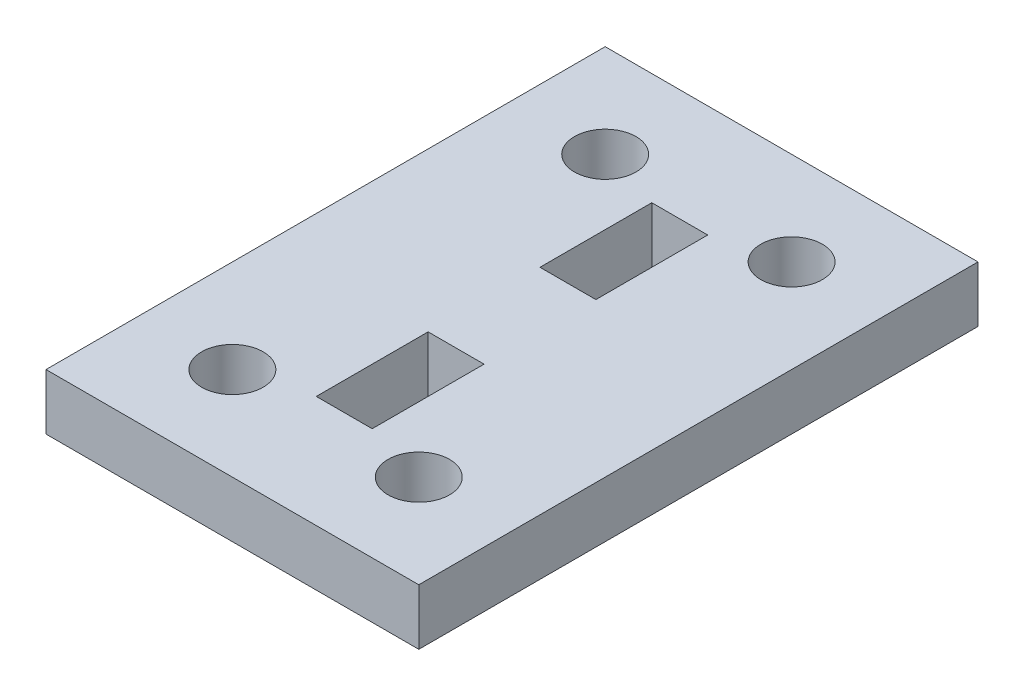
from build123d import *

# Parameters (mm, degrees)
SKETCH1_W           = 20
SKETCH1_H           = 30
SKETCH1_R           = 1.65
SKETCH1_W_2         = 3
SKETCH1_H_2         = 6
BOSS_EXTRUDE1_DEPTH = 3


with BuildPart() as part:
    # Sketch1 → Boss-Extrude1 (new body)
    with BuildSketch(Plane(origin=(0, 0, 0), x_dir=(1, 0, 0), z_dir=(0, 1, 0))):
        Rectangle(SKETCH1_W, SKETCH1_H)
        with Locations((-5, -10)):
            Circle(SKETCH1_R, mode=Mode.SUBTRACT)
        with Locations((5, -10)):
            Circle(SKETCH1_R, mode=Mode.SUBTRACT)
        with Locations((5, 10)):
            Circle(SKETCH1_R, mode=Mode.SUBTRACT)
        with Locations((-5, 10)):
            Circle(SKETCH1_R, mode=Mode.SUBTRACT)
        with Locations((0, 6)):
            Rectangle(SKETCH1_W_2, SKETCH1_H_2, mode=Mode.SUBTRACT)
        with Locations((0, -6)):
            Rectangle(SKETCH1_W_2, SKETCH1_H_2, mode=Mode.SUBTRACT)
    extrude(amount=BOSS_EXTRUDE1_DEPTH)


solid = part.part
